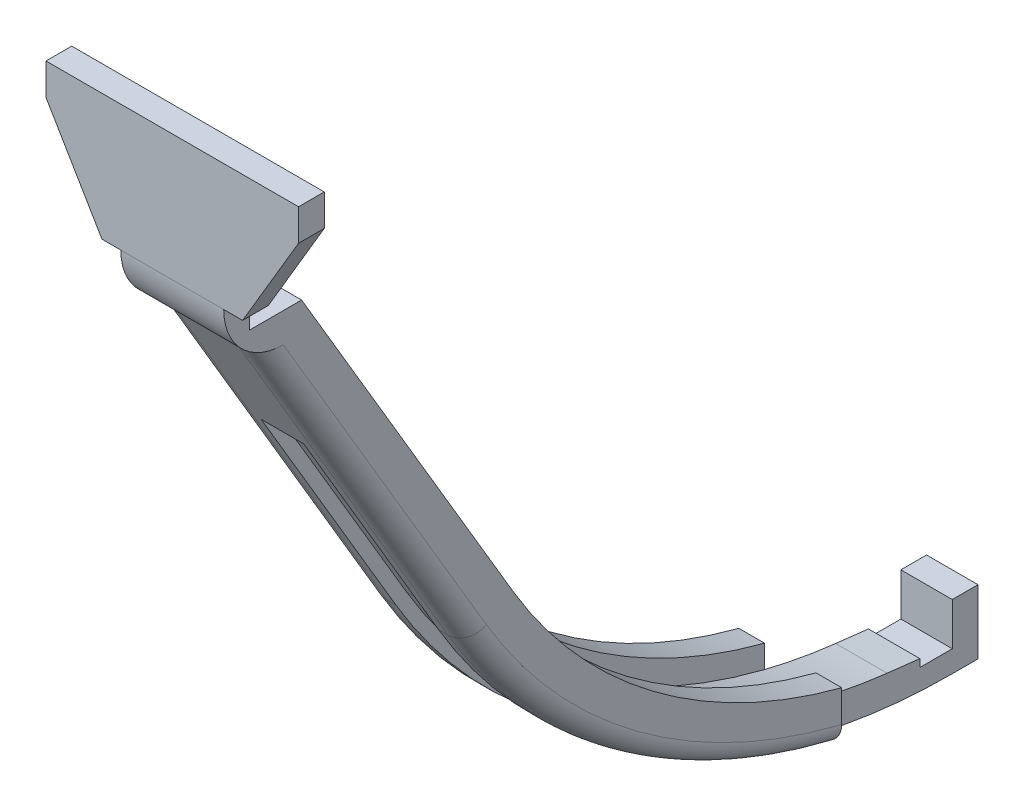
from build123d import *

# Parameters (mm, degrees)
SKETCH5_W           = 12.880016042
SKETCH5_H           = 15.834691301
CUT_EXTRUDE2_DEPTH  = 7.62
CUT_EXTRUDE6_REACH  = 62
SKETCH11_W          = 3.175
SKETCH11_H          = 3.175
BOSS_EXTRUDE1_DEPTH = 6.35
CUT_EXTRUDE4_DEPTH  = 3.175
SKETCH10_W          = 4
SKETCH10_H          = 0.5
CUT_EXTRUDE5_DEPTH  = 37.349999944
CUT_EXTRUDE7_DEPTH  = 40.64
BOSS_EXTRUDE3_DEPTH = 12.7
SKETCH19_W          = 21.319602533
SKETCH19_H          = 36.10119369
CUT_EXTRUDE10_DEPTH = 13.7
SKETCH21_W          = 9.2375
SKETCH21_H          = 12.42619369
SKETCH21_H_2        = 3.175
BOSS_EXTRUDE4_DEPTH = 3.175
SKETCH17_W          = 3.175
SKETCH17_H          = 52.572237063
CUT_EXTRUDE9_DEPTH  = 20
CUT_EXTRUDE11_DEPTH = 4.175
CUT_EXTRUDE12_DEPTH = 2.625
FILLET1_R           = 2.54


with BuildPart() as part:
    # Sketch2 → Revolve1 (revolve)
    with BuildSketch(Plane(origin=(0, 0, 0), x_dir=(0, 0, -1), z_dir=(1, 0, 0))):
        Polygon((0, -50.8), (-29.999999944, 0), (0, 0), align=None)
    revolve(axis=Axis((0, 0, 0), (0, -1, 0)))

    # Sketch4 → Cut-Revolve1 (revolve, cut)
    with BuildSketch(Plane(origin=(0, 0, 0), x_dir=(0, 0, -1), z_dir=(1, 0, 0))):
        Polygon((0, -45.72), (-24.919999944, 0), (0, 0), align=None)
    revolve(axis=Axis((0, 16.11457811, 0), (0, -1, 0)), mode=Mode.SUBTRACT)

    # Sketch5 → Cut-Extrude2 (cut, symmetric)
    with BuildSketch(Plane(origin=(0, 0, 0), x_dir=(0, 0, -1), z_dir=(1, 0, 0))):
        with Locations((0, -47.812265381)):
            Rectangle(SKETCH5_W, SKETCH5_H)
    extrude(amount=CUT_EXTRUDE2_DEPTH, both=True, mode=Mode.SUBTRACT)

    # Sketch11 → Cut-Extrude6 (cut, up to next)
    with BuildSketch(Plane.XY.offset(29.999999944), mode=Mode.PRIVATE) as cut_extrude6_sk1:
        with Locations((4.7625, -1.5875)):
            Rectangle(SKETCH11_W, SKETCH11_H)
    cut_extrude6_tool1 = extrude(cut_extrude6_sk1.sketch, amount=-CUT_EXTRUDE6_REACH, mode=Mode.PRIVATE) & part.part
    add(cut_extrude6_tool1.solids().sort_by_distance((4.7625, -1.5875, 30))[0], mode=Mode.SUBTRACT)
    # Sketch11 → Cut-Extrude6 (cut, up to next)
    with BuildSketch(Plane.XY.offset(29.999999944), mode=Mode.PRIVATE) as cut_extrude6_sk2:
        with Locations((-4.7625, -1.5875)):
            Rectangle(SKETCH11_W, SKETCH11_H)
    cut_extrude6_tool2 = extrude(cut_extrude6_sk2.sketch, amount=-CUT_EXTRUDE6_REACH, mode=Mode.PRIVATE) & part.part
    add(cut_extrude6_tool2.solids().sort_by_distance((-4.7625, -1.5875, 30))[0], mode=Mode.SUBTRACT)

    # Sketch6 → Boss-Extrude1 (add, symmetric)
    with BuildSketch(Plane(origin=(0, 0, 0), x_dir=(0, 0, -1), z_dir=(1, 0, 0))):
        with BuildLine():
            Line((0, -39.89491973), (-7.374618631, -39.89491973))
            Line((-7.374618631, -39.89491973), (20.618728491, -87.296987611))
            ThreePointArc((20.618728491, -87.296987611), (38.876637468, -107.970587413), (63.5, -120.397935747))
            ThreePointArc((63.5, -120.397935747), (73.403024923, -122.48861576), (83.5, -123.19))
            Line((83.5, -123.19), (86.675, -123.19))
            Line((86.675, -123.19), (86.675, -115.2525))
            Line((86.675, -115.2525), (83.5, -115.2525))
            Line((83.5, -115.2525), (83.5, -116.84))
            ThreePointArc((83.5, -116.84), (50.445813134, -108.070287624), (26.086468861, -84.068007083))
            Line((26.086468861, -84.068007083), (0, -39.89491973))
        make_face()
        Polygon((-30.934610553, 0), (-7.374618631, -39.89491973), (0, -39.89491973), (-23.559991923, 0), align=None)
    extrude(amount=BOSS_EXTRUDE1_DEPTH, both=True)

    # Sketch7 → Cut-Extrude4 (cut)
    with BuildSketch(Plane(origin=(0, 0, 0), x_dir=(0, 0, -1), z_dir=(1, 0, 0))):
        with BuildLine():
            Line((-3.175, -39.89491973), (23.732438565, -85.458182452))
            ThreePointArc((23.732438565, -85.458182452), (45.650201216, -108.346121156), (75.457309, -119.106343424))
            ThreePointArc((75.457309, -119.106343424), (79.477830242, -119.567967375), (83.5, -120.015))
            Line((83.5, -120.015), (83.5, -116.84))
            ThreePointArc((83.5, -116.84), (50.445813134, -108.070287624), (26.086468861, -84.068007083))
            Line((26.086468861, -84.068007083), (-23.559991923, 0))
            Line((-23.559991923, 0), (-26.734991923, 0))
            Line((-26.734991923, 0), (-3.175, -39.89491973))
        make_face()
    cut_extrude4 = extrude(amount=-CUT_EXTRUDE4_DEPTH, mode=Mode.SUBTRACT)

    # Mirror1: Cut-Extrude4 across plane
    add(cut_extrude4.mirror(Plane(origin=(0, 0, 0), x_dir=(0, 0, 1), z_dir=(1, 0, 0))), mode=Mode.SUBTRACT)

    # Sketch9 → Cut-Revolve2 (revolve, cut)
    with BuildSketch(Plane(origin=(0, 0, 0), x_dir=(0, 0, -1), z_dir=(1, 0, 0))):
        Polygon((0, 0), (-24.9199908, 0), (-0.536470716, -39.89491973), (0, -39.89491973), align=None)
    revolve(axis=Axis((0, 16.11457811, 0), (0, -1, 0)), mode=Mode.SUBTRACT)

    # Sketch10 → Cut-Extrude5 (cut, through all)
    with BuildSketch(Plane.ZY.offset(6.35)):
        with BuildLine():
            Line((-79.5, -120.015), (-79.5, -116.719911574))
            ThreePointArc((-79.5, -116.719911574), (-81.499098876, -116.809971132), (-83.5, -116.84))
            Line((-83.5, -116.84), (-83.5, -120.015))
            Line((-83.5, -120.015), (-79.5, -120.015))
        make_face()
        with Locations((-81.5, -120.265)):
            Rectangle(SKETCH10_W, SKETCH10_H)
    extrude(amount=-CUT_EXTRUDE5_DEPTH, mode=Mode.SUBTRACT)

    # Sketch12 → Cut-Extrude7 (cut, symmetric)
    with BuildSketch(Plane.ZY):
        Polygon((30, 0), (-29.999999944, 0), (-29.999999944, -39.89491973), (-6.440008021, -39.89491973), (6.44000802, -39.89491973), align=None)
    extrude(amount=CUT_EXTRUDE7_DEPTH, both=True, mode=Mode.SUBTRACT)

    # Sketch18 → Boss-Extrude3 (add)
    with BuildSketch(Plane.ZY.offset(6.35)):
        with BuildLine():
            Line((6.44000802, -39.89491973), (6.44000802, -20.5))
            Line((6.44000802, -20.5), (9.61500802, -20.5))
            Line((9.61500802, -20.5), (9.61500802, -34.5185864))
            Line((9.61500802, -34.5185864), (9.61500802, -36.10119369))
            ThreePointArc((9.61500802, -36.10119369), (8.57844205, -39.89491973), (5.756782033, -42.634456374))
            Line((5.756782033, -42.634456374), (6.44000802, -41.477527034))
            Line((6.44000802, -41.477527034), (6.44000802, -39.89491973))
        make_face()
    extrude(amount=-BOSS_EXTRUDE3_DEPTH)

    # Sketch19 → Cut-Extrude10 (cut, through all)
    with BuildSketch(Plane.ZY.offset(6.35)):
        with Locations((20.274809287, -18.050596845)):
            Rectangle(SKETCH19_W, SKETCH19_H)
    extrude(amount=-CUT_EXTRUDE10_DEPTH, mode=Mode.SUBTRACT)

    # Sketch21 → Boss-Extrude4 (add)
    with BuildSketch(Plane.XY.offset(9.61500802)):
        with Locations((-10.96875, -29.888096845)):
            Rectangle(SKETCH21_W, SKETCH21_H)
        with Locations((10.96875, -29.888096845)):
            Rectangle(SKETCH21_W, SKETCH21_H)
        with Locations((10.96875, -22.0875)):
            Rectangle(SKETCH21_W, SKETCH21_H_2)
        with Locations((-10.96875, -22.0875)):
            Rectangle(SKETCH21_W, SKETCH21_H_2)
    extrude(amount=-BOSS_EXTRUDE4_DEPTH)

    # Sketch17 → Cut-Extrude9 (cut)
    with BuildSketch(Plane(origin=(0, 0, -86.675), x_dir=(-1, 0, 0), z_dir=(0, 0, -1))):
        with Locations((-4.7625, -96.903881469)):
            Rectangle(SKETCH17_W, SKETCH17_H)
        with Locations((4.7625, -96.903881469)):
            Rectangle(SKETCH17_W, SKETCH17_H)
    extrude(amount=-CUT_EXTRUDE9_DEPTH, mode=Mode.SUBTRACT)

    # Sketch22 → Cut-Extrude11 (cut, through all)
    with BuildSketch(Plane(origin=(0, 0, 6.44000802), x_dir=(-1, 0, 0), z_dir=(0, 0, -1))):
        Polygon((-15.5875, -24.405166536), (-15.5875, -36.10119369), (-8.680397482, -36.10119369), align=None)
        Polygon((15.5875, -24.405166536), (8.680397482, -36.10119369), (15.5875, -36.10119369), align=None)
    extrude(amount=-CUT_EXTRUDE11_DEPTH, mode=Mode.SUBTRACT)

    # Sketch24 → Cut-Extrude12 (cut, symmetric)
    with BuildSketch(Plane(origin=(0, 0, 0), x_dir=(0, 0, -1), z_dir=(1, 0, 0))):
        with BuildLine():
            Line((3.985949874, -59.1321491), (20.618728491, -87.296987611))
            ThreePointArc((20.618728491, -87.296987611), (40.186529767, -108.958439573), (66.675, -121.22539896))
            Line((66.675, -121.22539896), (66.675, -119.683023005))
            ThreePointArc((66.675, -119.683023005), (40.93327594, -107.645198887), (21.910320704, -86.534236305))
            Line((21.910320704, -86.534236305), (5.277542087, -58.369397794))
            Line((5.277542087, -58.369397794), (3.985949874, -59.1321491))
        make_face()
    extrude(amount=CUT_EXTRUDE12_DEPTH, both=True, mode=Mode.SUBTRACT)

    # Fillet1
    fillet1_edges = [part.edges().sort_by_distance(p)[0] for p in [
        (6.35, -64.965721992, -7.430973229),
        (6.35, -108.958439573, -40.186529767),
        (-6.35, -64.965721992, -7.430973229),
        (-6.35, -108.958439573, -40.186529767),
    ]]
    fillet(fillet1_edges, radius=FILLET1_R)


solid = part.part
